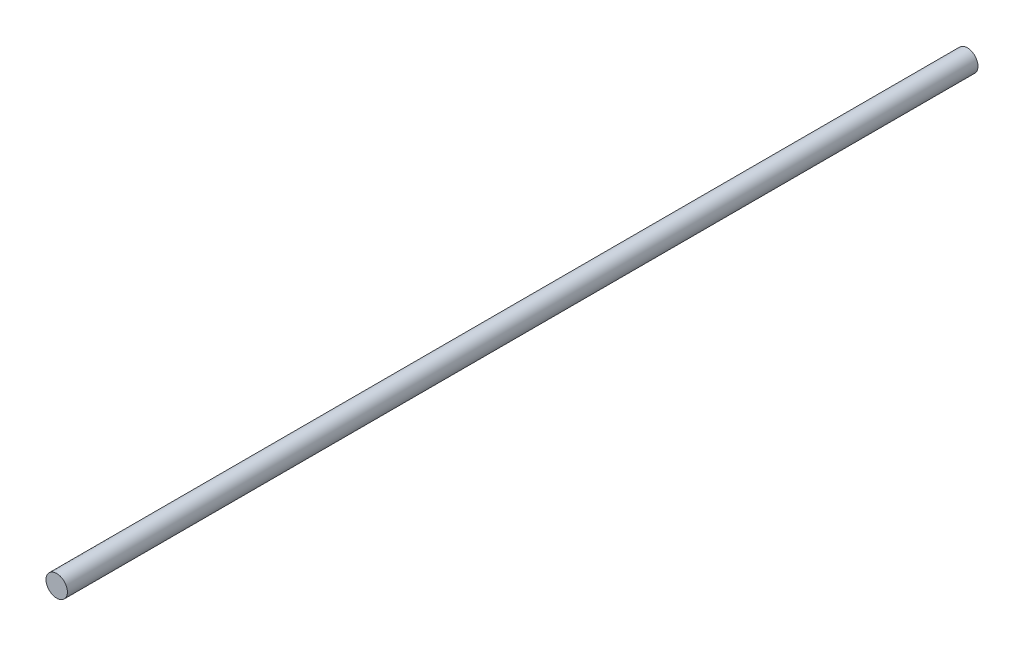
from build123d import *

# Parameters (mm, degrees)
ESQUISSE1_R        = 1
BOSS_EXTRU_1_DEPTH = 85


with BuildPart() as part:
    # Esquisse1 → Boss.-Extru.1 (new body)
    with BuildSketch(Plane.XY):
        Circle(ESQUISSE1_R)
    extrude(amount=BOSS_EXTRU_1_DEPTH)


solid = part.part
